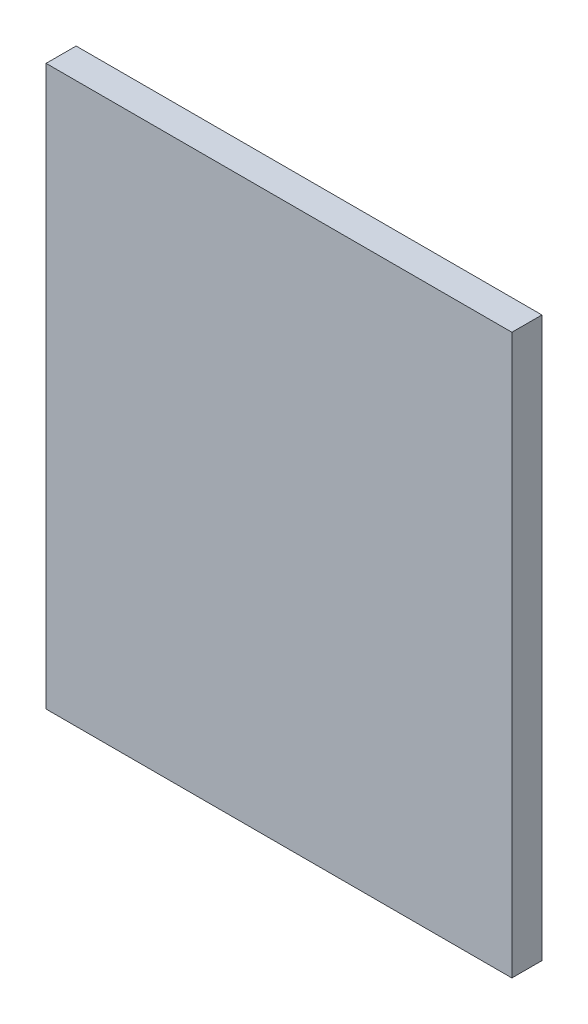
from build123d import *

# Parameters (mm, degrees)
SKETCH1_W           = 6.980000001
SKETCH1_H           = 8.380000002
BOSS_EXTRUDE1_DEPTH = 0.45


with BuildPart() as part:
    # Sketch1 → Boss-Extrude1 (new body)
    with BuildSketch(Plane(origin=(0, 0, 0), x_dir=(-1, 0, 0), z_dir=(0, 0, -1))):
        with Locations((-3.490000001, 4.190000001)):
            Rectangle(SKETCH1_W, SKETCH1_H)
    extrude(amount=-BOSS_EXTRUDE1_DEPTH)


solid = part.part
